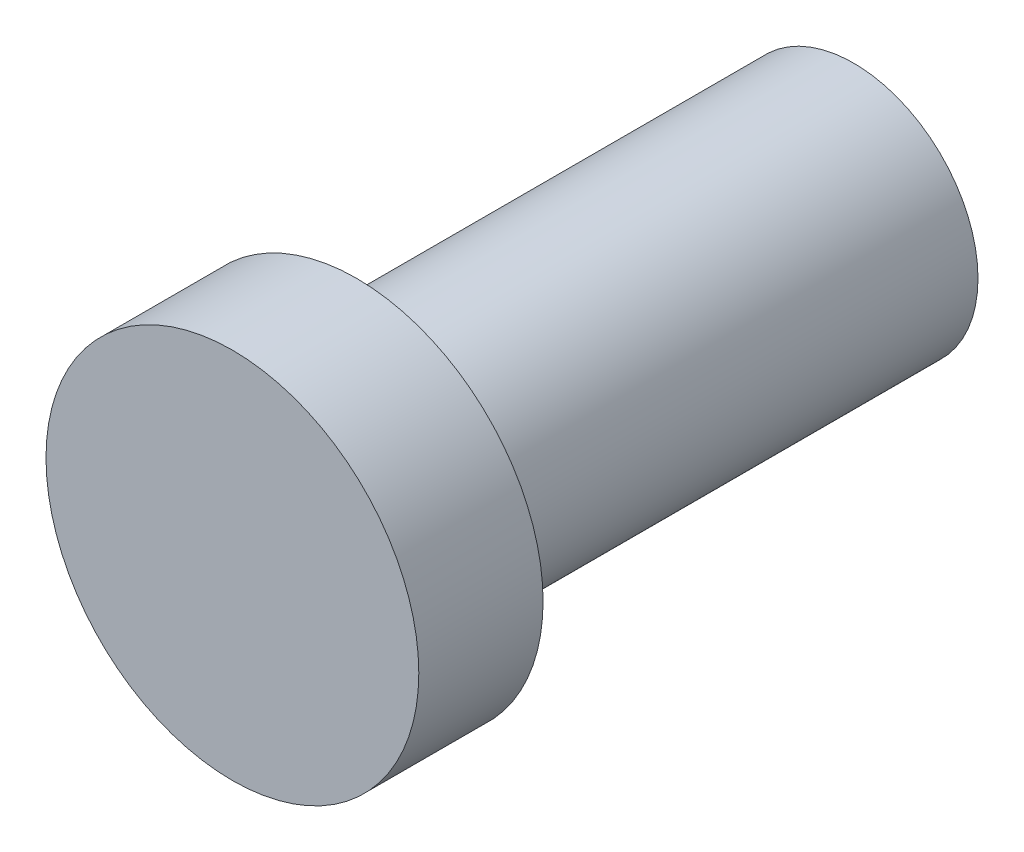
from build123d import *

# Parameters (mm, degrees)
CROQUIS1_R              = 6.35
SALIENTE_EXTRUIR1_DEPTH = 25.4
CROQUIS2_R              = 9.525
SALIENTE_EXTRUIR2_DEPTH = 6.35


with BuildPart() as part:
    # Croquis1 → Saliente-Extruir1 (new body)
    with BuildSketch(Plane.XY):
        Circle(CROQUIS1_R)
    extrude(amount=SALIENTE_EXTRUIR1_DEPTH)

    # Croquis2 → Saliente-Extruir2 (add)
    with BuildSketch(Plane.XY.offset(25.4)):
        Circle(CROQUIS2_R)
    extrude(amount=SALIENTE_EXTRUIR2_DEPTH)


solid = part.part
